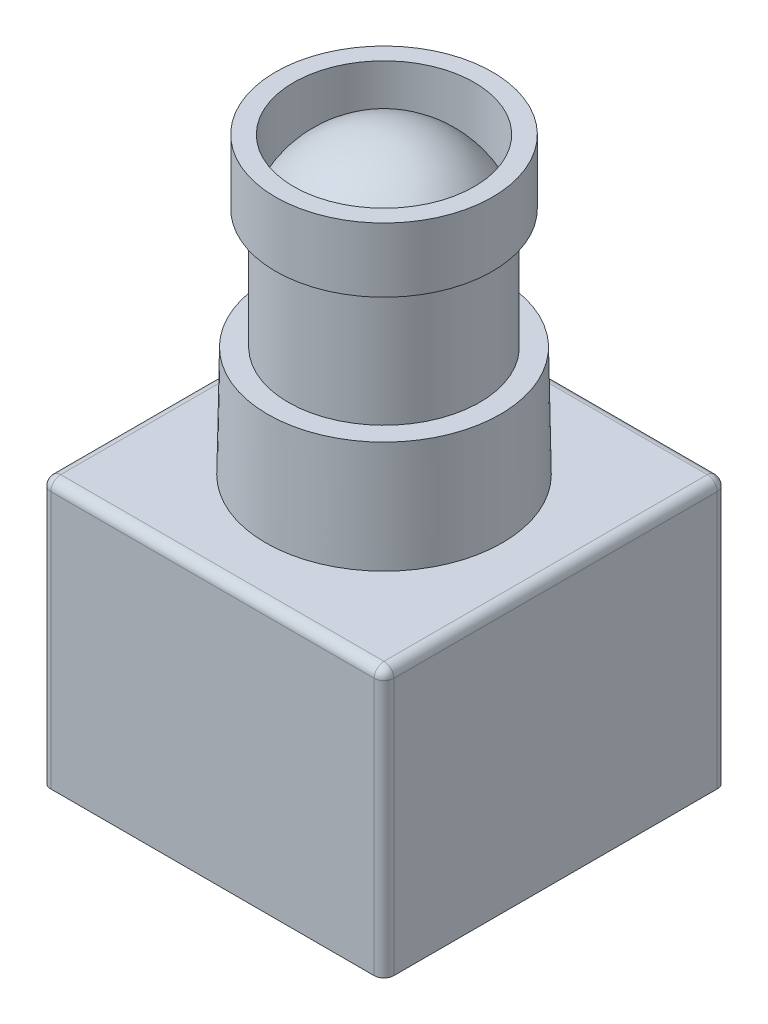
from build123d import *

# Parameters (mm, degrees)
SKETCH1_W         = 22.098
SKETCH1_H         = 22.098
EXTRUDE1_DEPTH    = 17.2212
FILLET1_R         = 0.635
SKETCH2_R         = 7.62
EXTRUDE2_DEPTH    = 7.112
EXTRUDE2_TAPER    = 1
SKETCH3_R         = 6.165117765
EXTRUDE3_DEPTH    = 7.7216
SKETCH4_R         = 6.985
EXTRUDE4_DEPTH    = 4.1402
SKETCH5_R         = 5.817229734
EXTRUDE5_DEPTH    = 3.683
DOME1_FACE_RADIUS = 5.817229734
DOME1_HEIGHT      = 3.683


with BuildPart() as part:
    # Sketch1 → Extrude1 (new body)
    with BuildSketch(Plane(origin=(0, 0, 0), x_dir=(1, 0, 0), z_dir=(0, 1, 0))):
        with Locations((11.049, 11.049)):
            Rectangle(SKETCH1_W, SKETCH1_H)
    extrude(amount=EXTRUDE1_DEPTH)

    # Fillet1
    fillet1_edges = [part.edges().sort_by_distance(p)[0] for p in [
        (22.098, 17.2212, -11.049),
        (11.049, 17.2212, -22.098),
        (0, 17.2212, -11.049),
        (11.049, 17.2212, 0),
        (0, 8.6106, -22.098),
        (22.098, 8.6106, -22.098),
        (22.098, 8.6106, 0),
        (0, 8.6106, 0),
    ]]
    fillet(fillet1_edges, radius=FILLET1_R)

    # Sketch2 → Extrude2 (add)
    with BuildSketch(Plane(origin=(0, 17.2212, 0), x_dir=(1, 0, 0), z_dir=(0, 1, 0))):
        with Locations((11.049, 11.049)):
            Circle(SKETCH2_R)
    extrude(amount=EXTRUDE2_DEPTH, taper=EXTRUDE2_TAPER)

    # Sketch3 → Extrude3 (add)
    with BuildSketch(Plane(origin=(0, 24.3332, 0), x_dir=(1, 0, 0), z_dir=(0, 1, 0))):
        with Locations((11.049, 11.049)):
            Circle(SKETCH3_R)
    extrude(amount=EXTRUDE3_DEPTH)

    # Sketch4 → Extrude4 (add)
    with BuildSketch(Plane(origin=(0, 32.0548, 0), x_dir=(1, 0, 0), z_dir=(0, 1, 0))):
        with Locations((11.049, 11.049)):
            Circle(SKETCH4_R)
    extrude(amount=EXTRUDE4_DEPTH)

    # Sketch5 → Extrude5 (cut)
    with BuildSketch(Plane(origin=(0, 36.195, 0), x_dir=(1, 0, 0), z_dir=(0, 1, 0))):
        with Locations((11.049, 11.049)):
            Circle(SKETCH5_R)
    extrude(amount=-EXTRUDE5_DEPTH, mode=Mode.SUBTRACT)

    # Dome1: a dome of height H over a round flat face of radius A is a cap of a sphere of radius (A * A + H * H) / (2 * H)
    dome1_r = (DOME1_FACE_RADIUS * DOME1_FACE_RADIUS + DOME1_HEIGHT * DOME1_HEIGHT) / (2 * DOME1_HEIGHT)
    dome1_base = Plane((11.049, 32.512, -11.049), z_dir=(0, 1, 0))
    with Locations(dome1_base.offset(DOME1_HEIGHT - dome1_r)):
        dome1_ball = Sphere(dome1_r, mode=Mode.PRIVATE)
    add(split(dome1_ball, bisect_by=dome1_base, keep=Keep.TOP, mode=Mode.PRIVATE))


solid = part.part
